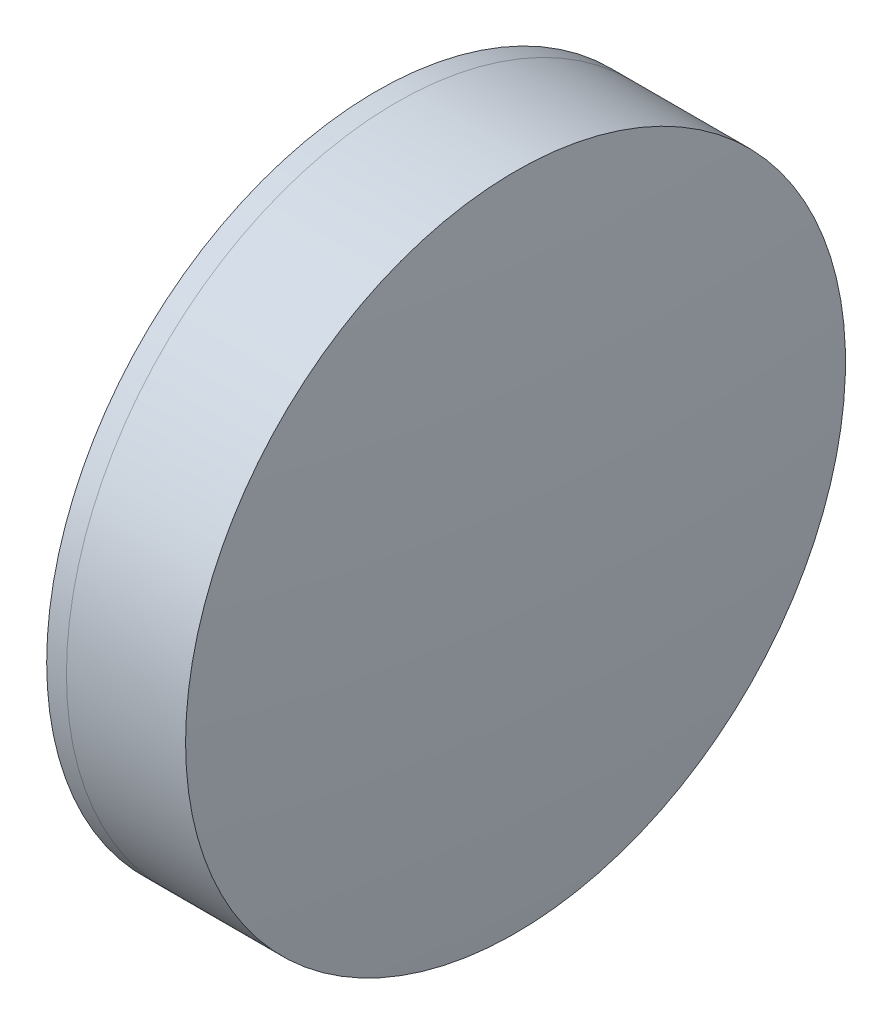
from build123d import *


with BuildPart() as part:
    # 草图1 one side → 旋转1 (revolve)
    with BuildSketch(Plane(origin=(0, 0, 0), x_dir=(1, 0, 0), z_dir=(0, 1, 0)), mode=Mode.PRIVATE) as revolve_1_sk:
        with BuildLine():
            ThreePointArc((205.288208134, 15), (202.68390408, 7.700066605), (201.800500739, 0))
            Line((201.800500739, 0), (210.300500739, 0))
            ThreePointArc((210.300500739, 0), (209.253240719, 7.777026141), (206.186069746, 15))
            Line((206.186069746, 15), (205.288208134, 15))
        make_face()
    revolve(revolve_1_sk.sketch.rotate(Axis((124.523309526, 0, 0), (1, 0, 0)), 180), axis=Axis((124.523309526, 0, 0), (1, 0, 0)))  # turned: the seam where the file's is


with BuildPart() as body_2:
    # 草图2 one side → 旋转3 (revolve)
    with BuildSketch(Plane(origin=(0, 0, 0), x_dir=(1, 0, 0), z_dir=(0, 1, 0)), mode=Mode.PRIVATE) as revolve_3_sk:
        with BuildLine():
            Line((211.602397494, 15), (206.186069746, 15))
            ThreePointArc((206.186069746, 15), (209.253240719, 7.777026141), (210.300500739, 0))
            Line((210.300500739, 0), (212.300500739, 0))
            ThreePointArc((212.300500739, 0), (212.125880524, 7.508118075), (211.602397494, 15))
        make_face()
    revolve(revolve_3_sk.sketch.rotate(Axis((-0.551919993, 0, 0), (1, 0, 0)), 180), axis=Axis((-0.551919993, 0, 0), (1, 0, 0)))  # turned: the seam where the file's is


solid = Compound([part.part, body_2.part])
